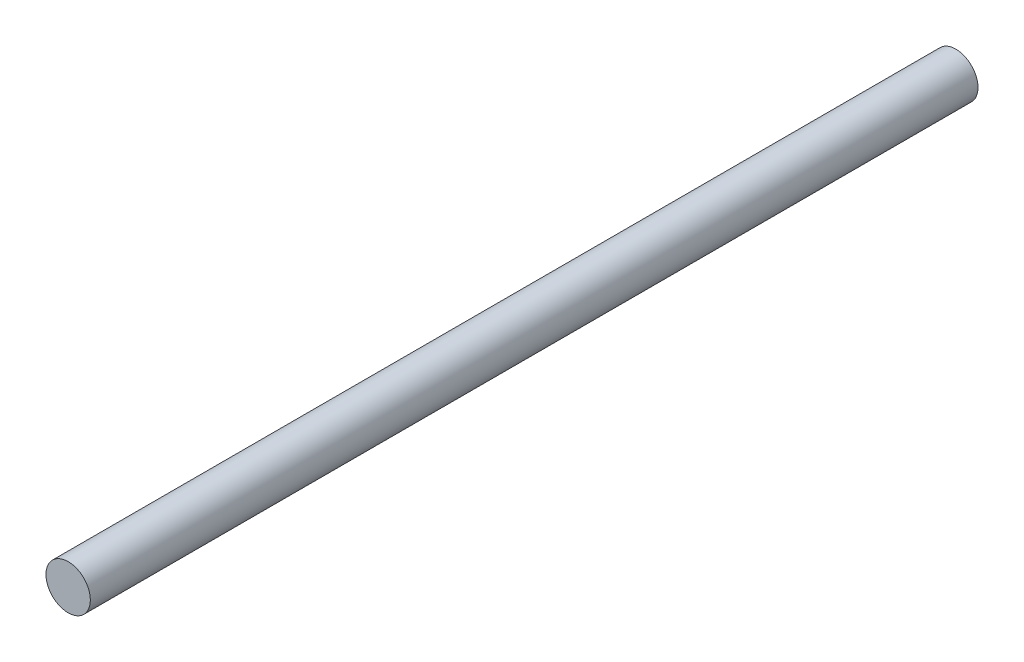
from build123d import *

# Parameters (mm, degrees)
SKETCH1_R           = 3.175
BOSS_EXTRUDE1_DEPTH = 127


with BuildPart() as part:
    # Sketch1 → Boss-Extrude1 (new body)
    with BuildSketch(Plane.XY):
        Circle(SKETCH1_R)
    extrude(amount=BOSS_EXTRUDE1_DEPTH)


solid = part.part
